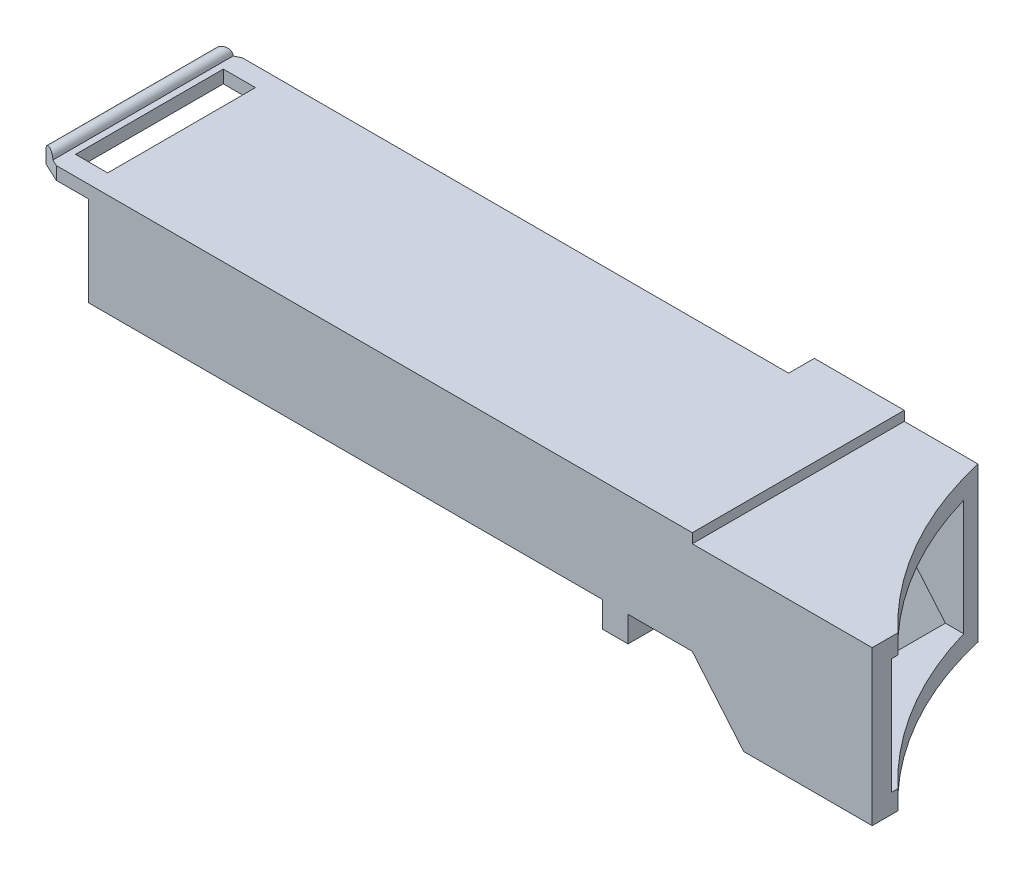
from build123d import *

# Parameters (mm, degrees)
RESSALTO_EXTRUS_O1_DEPTH   = 16.5
CORTE_EXTRUS_O3_DEPTH      = 1
CORTE_EXTRUS_O3_DEPTH_BACK = 13.75
CASCA1_T                   = -1.5
CORTE_EXTRUS_O2_DEPTH      = 13.75
ESBO_O6_W                  = 60.936281692
ESBO_O6_H                  = 31.71485299
CORTE_EXTRUS_O4_DEPTH      = 3
CORTE_EXTRUS_O4_DEPTH_BACK = 15.5
RESSALTO_EXTRUS_O2_DEPTH   = 14.5
ESBO_O8_W                  = 2.5
ESBO_O8_H                  = 11.5
CORTE_EXTRUS_O5_DEPTH      = 10
ESBO_O9_W                  = 2
ESBO_O9_H                  = 2
RESSALTO_EXTRUS_O3_DEPTH   = 2
ESBO_O10_W                 = 2
ESBO_O10_H                 = 2
RESSALTO_EXTRUS_O4_DEPTH   = 8


with BuildPart() as part:
    # Esboço1 → Ressalto-extrusão1 (new body)
    with BuildSketch(Plane.XY):
        with BuildLine():
            Line((9.53089658, 0), (70, 0))
            Line((70, 0), (70, -0.75))
            Line((70, -0.75), (84, -0.75))
            Line((84, -0.75), (84, -12.75))
            Line((84, -12.75), (74, -12.75))
            Line((74, -12.75), (70, -8))
            Line((70, -8), (6.002125959, -8))
            Line((6.002125959, -8), (5.638155725, -9))
            Line((5.638155725, -9), (0, -6.94787914))
            Line((0, -6.94787914), (0.133970372, -6.579798567))
            ThreePointArc((0.133970372, -6.579798567), (3.795132217, -1.808479557), (9.53089658, 0))
        make_face()
    extrude(amount=RESSALTO_EXTRUS_O1_DEPTH)

    # Esboço5 → Corte-extrusão3 (cut, two sides)
    with BuildSketch(Plane.XZ.offset(12.75)) as corte_extrus_o3_sk:
        Polygon((0, 0), (65, 0), (63, 2), (0, 2), align=None)
    extrude(amount=CORTE_EXTRUS_O3_DEPTH, mode=Mode.SUBTRACT)
    extrude(corte_extrus_o3_sk.sketch, amount=-CORTE_EXTRUS_O3_DEPTH_BACK, mode=Mode.SUBTRACT)

    # Casca1
    casca1_openings = [part.faces().sort_by_distance(p)[0] for p in [
        (84, -6.75, 8.25),
        (2.819077862, -7.97393957, 9.25),
    ]]
    offset(amount=CASCA1_T, openings=casca1_openings, kind=Kind.INTERSECTION)

    # Esboço4 → Corte-extrusão2 (cut, through all)
    with BuildSketch(Plane.XZ.offset(12.75)):
        with BuildLine():
            Line((75.737834478, 0), (84, 0))
            Line((84, 0), (84, 14.5))
            ThreePointArc((84, 14.5), (78.803340396, 7.8571705), (75.737834478, 0))
        make_face()
    extrude(amount=-CORTE_EXTRUS_O2_DEPTH, mode=Mode.SUBTRACT)

    # Esboço6 → Corte-extrusão4 (cut, two sides)
    with BuildSketch(Plane(origin=(0, 0, 2), x_dir=(-1, 0, 0), z_dir=(0, 0, -1))) as corte_extrus_o4_sk:
        with Locations((7.468140846, -5.914756455)):
            Rectangle(ESBO_O6_W, ESBO_O6_H)
    extrude(amount=CORTE_EXTRUS_O4_DEPTH, mode=Mode.SUBTRACT)
    extrude(corte_extrus_o4_sk.sketch, amount=-CORTE_EXTRUS_O4_DEPTH_BACK, mode=Mode.SUBTRACT)

    # Esboço7 → Ressalto-extrusão2 (add)
    with BuildSketch(Plane.XY.offset(16.5)):
        with BuildLine():
            Line((23, 0), (20, 0))
            ThreePointArc((20, 0), (19.5, 0.5), (19, 0))
            Line((19, 0), (19, -1))
            Line((19, -1), (23, -1))
            Line((23, -1), (23, 0))
        make_face()
    extrude(amount=-RESSALTO_EXTRUS_O2_DEPTH)

    # Esboço8 → Corte-extrusão5 (cut)
    with BuildSketch(Plane.XZ.offset(1)):
        with Locations((21.75, 9.25)):
            Rectangle(ESBO_O8_W, ESBO_O8_H)
        Polygon((20.5, 16.5), (19, 16.5), (19, 15.8), align=None)
        Polygon((19, 2.7), (20.5, 2), (19, 2), align=None)
    extrude(amount=-CORTE_EXTRUS_O5_DEPTH, mode=Mode.SUBTRACT)

    # Esboço9 → Ressalto-extrusão3 (add)
    with BuildSketch(Plane.XZ.offset(8)):
        with Locations((64, 15.5)):
            Rectangle(ESBO_O9_W, ESBO_O9_H)
    extrude(amount=RESSALTO_EXTRUS_O3_DEPTH)

    # Esboço10 → Ressalto-extrusão4 (add)
    with BuildSketch(Plane.XZ.offset(8)):
        with Locations((64, 1)):
            Rectangle(ESBO_O10_W, ESBO_O10_H)
    extrude(amount=-RESSALTO_EXTRUS_O4_DEPTH)


solid = part.part
